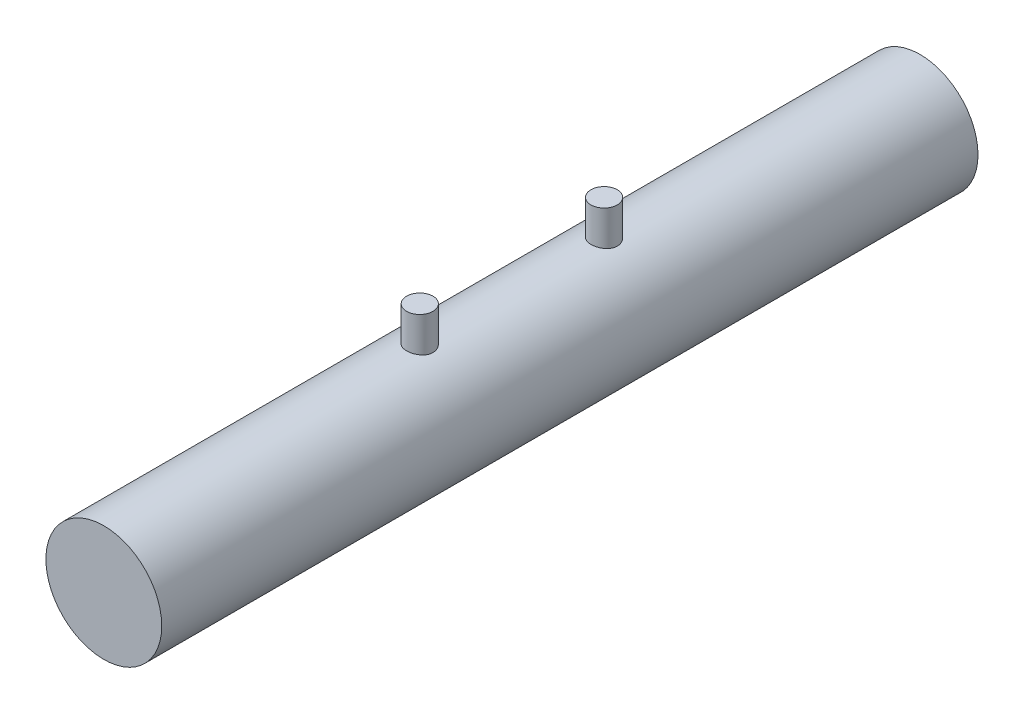
from build123d import *

# Parameters (mm, degrees)
ESBO_O1_R                = 110
RESSALTO_EXTRUS_O1_DEPTH = 1550
RESSALTO_EXTRUS_O2_REACH = 287
ESBO_O3_R                = 25


with BuildPart() as part:
    # Esboço1 → Ressalto-extrusão1 (new body)
    with BuildSketch(Plane.XY):
        Circle(ESBO_O1_R)
    extrude(amount=RESSALTO_EXTRUS_O1_DEPTH)

    # Esboço3 → Ressalto-extrusão2 (add, up to next)
    with BuildSketch(Plane(origin=(0, 175, 0), x_dir=(1, 0, 0), z_dir=(0, 1, 0)), mode=Mode.PRIVATE) as ressalto_extrus_o2_sk1:
        with Locations((0, -600)):
            Circle(ESBO_O3_R)
    ressalto_extrus_o2_tool1 = extrude(ressalto_extrus_o2_sk1.sketch, amount=-RESSALTO_EXTRUS_O2_REACH, mode=Mode.PRIVATE) - part.part
    add(ressalto_extrus_o2_tool1.solids().sort_by_distance((0, 175, 600))[0])
    # Esboço3 → Ressalto-extrusão2 (add, up to next)
    with BuildSketch(Plane(origin=(0, 175, 0), x_dir=(1, 0, 0), z_dir=(0, 1, 0)), mode=Mode.PRIVATE) as ressalto_extrus_o2_sk2:
        with Locations((0, -950)):
            Circle(ESBO_O3_R)
    ressalto_extrus_o2_tool2 = extrude(ressalto_extrus_o2_sk2.sketch, amount=-RESSALTO_EXTRUS_O2_REACH, mode=Mode.PRIVATE) - part.part
    add(ressalto_extrus_o2_tool2.solids().sort_by_distance((0, 175, 950))[0])


solid = part.part
